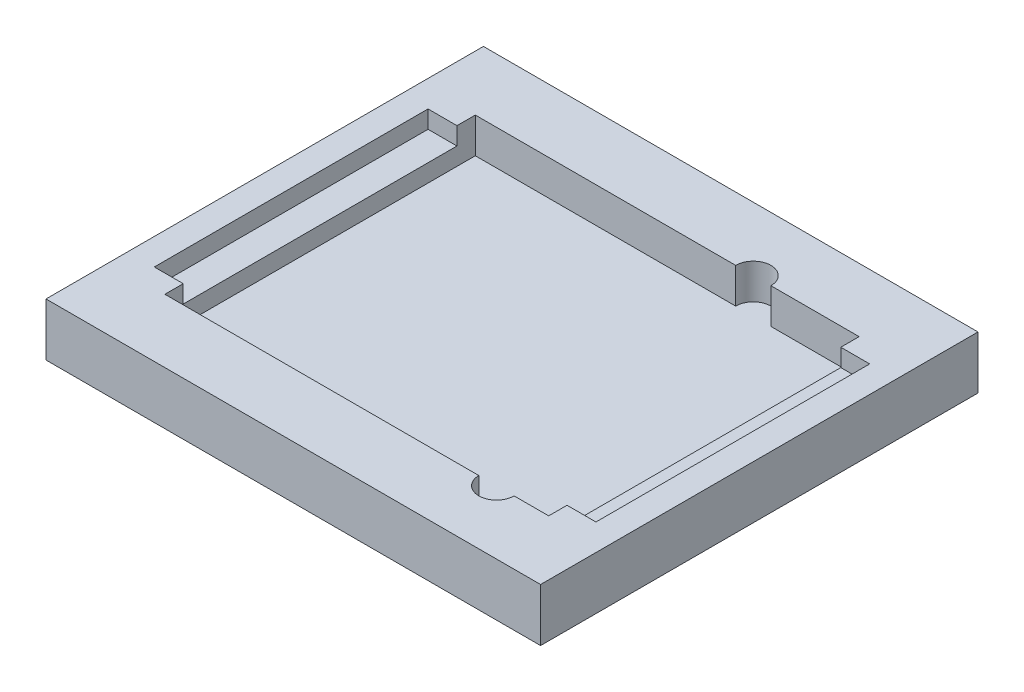
from build123d import *

# Parameters (mm, degrees)
BOSS_EXTRUDE1_DEPTH = 3.175
SKETCH2_W           = 89.027
SKETCH2_H           = 78.74
BOSS_EXTRUDE2_DEPTH = 6.35
CUT_EXTRUDE1_DEPTH  = 3.175
SKETCH4_W           = 89.027
SKETCH4_H           = 78.74
BOSS_EXTRUDE3_DEPTH = 3.175


with BuildPart() as part:
    # Sketch1 → Boss-Extrude1 (new body)
    with BuildSketch(Plane(origin=(0, 0, 0), x_dir=(1, 0, 0), z_dir=(0, 1, 0))):
        with BuildLine():
            Line((2.54, 0), (80.01, 0))
            ThreePointArc((80.01, 0), (81.806051224, 0.743948776), (82.55, 2.54))
            Line((82.55, 2.54), (82.55, 69.596))
            ThreePointArc((82.55, 69.596), (81.806051224, 71.392051224), (80.01, 72.136))
            Line((80.01, 72.136), (2.54, 72.136))
            ThreePointArc((2.54, 72.136), (0.743948776, 71.392051224), (0, 69.596))
            Line((0, 69.596), (0, 2.54))
            ThreePointArc((0, 2.54), (0.743948776, 0.743948776), (2.54, 0))
        make_face()
    extrude(amount=BOSS_EXTRUDE1_DEPTH)

    # Sketch2 → Boss-Extrude2 (add)
    with BuildSketch(Plane(origin=(0, 3.175, 0), x_dir=(1, 0, 0), z_dir=(0, 1, 0))):
        with Locations((41.275, 36.068)):
            Rectangle(SKETCH2_W, SKETCH2_H)
    extrude(amount=BOSS_EXTRUDE2_DEPTH)

    # Sketch3 → Cut-Extrude1 (cut)
    with BuildSketch(Plane(origin=(0, 9.525, 0), x_dir=(1, 0, 0), z_dir=(0, 1, 0))):
        with BuildLine():
            Line((6.731, 8.128), (63.246, 8.128))
            ThreePointArc((63.246, 8.128), (66.421, 4.953), (69.596, 8.128))
            Line((69.596, 8.128), (75.819, 8.128))
            Line((75.819, 8.128), (75.819, 64.008))
            Line((75.819, 64.008), (59.944, 64.008))
            ThreePointArc((59.944, 64.008), (56.769, 67.183), (53.594, 64.008))
            Line((53.594, 64.008), (6.731, 64.008))
            Line((6.731, 64.008), (6.731, 8.128))
        make_face()
    extrude(amount=-CUT_EXTRUDE1_DEPTH, mode=Mode.SUBTRACT)

    # Sketch4 → Boss-Extrude3 (add)
    with BuildSketch(Plane(origin=(0, 9.525, 0), x_dir=(1, 0, 0), z_dir=(0, 1, 0))):
        with Locations((41.275, 36.068)):
            Rectangle(SKETCH4_W, SKETCH4_H)
        with BuildLine():
            Line((6.731, 11.43), (1.524, 11.43))
            Line((1.524, 11.43), (1.524, 60.706))
            Line((1.524, 60.706), (6.731, 60.706))
            Line((6.731, 60.706), (6.731, 64.008))
            Line((6.731, 64.008), (53.594, 64.008))
            ThreePointArc((53.594, 64.008), (56.769, 67.183), (59.944, 64.008))
            Line((59.944, 64.008), (75.819, 64.008))
            Line((75.819, 64.008), (75.819, 60.706))
            Line((75.819, 60.706), (81.026, 60.706))
            Line((81.026, 60.706), (81.026, 11.43))
            Line((81.026, 11.43), (75.819, 11.43))
            Line((75.819, 11.43), (75.819, 8.128))
            Line((75.819, 8.128), (69.596, 8.128))
            ThreePointArc((69.596, 8.128), (66.421, 4.953), (63.246, 8.128))
            Line((63.246, 8.128), (6.731, 8.128))
            Line((6.731, 8.128), (6.731, 11.43))
        make_face(mode=Mode.SUBTRACT)
    extrude(amount=BOSS_EXTRUDE3_DEPTH)


solid = part.part
